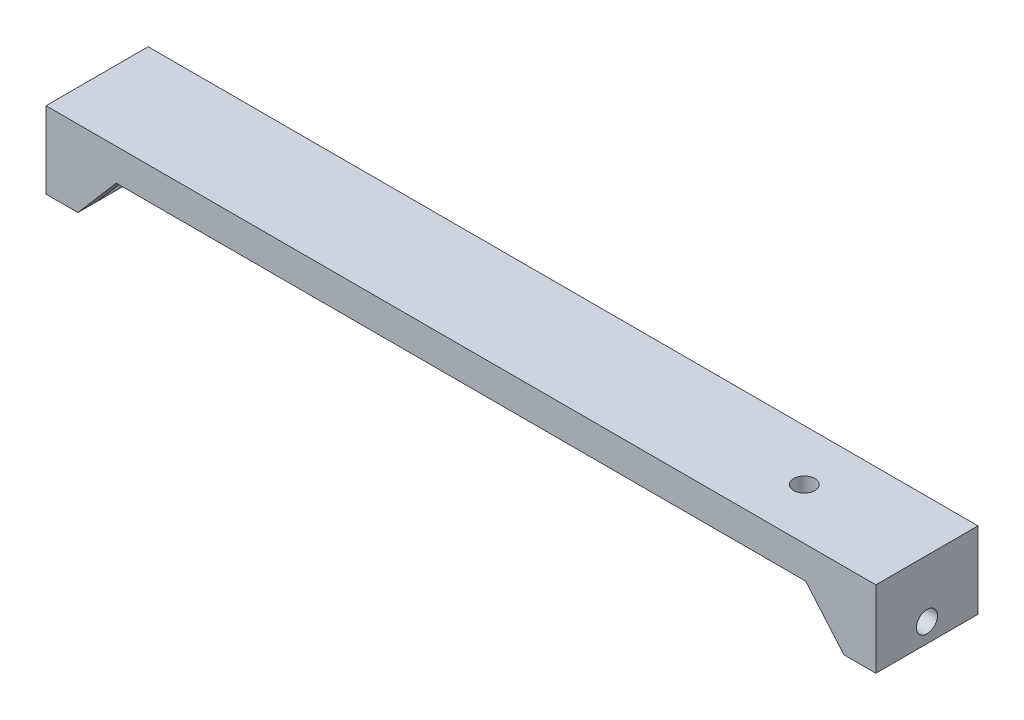
from build123d import *

# Parameters (mm, degrees)
EXTRUDE_2_DEPTH          = 16
SKETCH_3_R               = 1.65
CUT_EXTRUDE_1_DEPTH      = 126
CUT_EXTRUDE_1_DEPTH_BACK = 6
EXTRUDE_3_DEPTH          = 3
MIRROR_2_COPY_1_DEPTH    = 3
SKETCH_7_R               = 1.65
CUT_EXTRUDE_2_DEPTH      = 10


with BuildPart() as part:
    # 草图1 → 凸台-拉伸2 (new body)
    with BuildSketch(Plane.XY):
        Polygon((-65, 0), (65, 0), (65, -12), (60, -12), (60, -5), (-60, -5), (-60, -12), (-65, -12), align=None)
    extrude(amount=EXTRUDE_2_DEPTH)

    # 草图3 → 切除-拉伸1 (cut, two sides)
    with BuildSketch(Plane(origin=(-60, 0, 0), x_dir=(0, 0, -1), z_dir=(1, 0, 0))) as cut_extrude_1_sk:
        with Locations((-8, -9)):
            Circle(SKETCH_3_R)
    extrude(amount=CUT_EXTRUDE_1_DEPTH, mode=Mode.SUBTRACT)
    extrude(cut_extrude_1_sk.sketch, amount=-CUT_EXTRUDE_1_DEPTH_BACK, mode=Mode.SUBTRACT)

    # 草图4 → 凸台-拉伸3 (add)
    with BuildSketch(Plane(origin=(0, 0, 0), x_dir=(-1, 0, 0), z_dir=(0, 0, -1))):
        Polygon((54, -5), (60, -12), (60, -5), align=None)
    extrude_3 = extrude(amount=-EXTRUDE_3_DEPTH)

    # 镜向1: 凸台-拉伸3 across plane
    add(extrude_3.mirror(Plane.XY.offset(8)))

    # 镜向2: 凸台-拉伸3 across plane
    add(extrude_3.mirror(Plane(origin=(0, 0, 0), x_dir=(0, 0, 1), z_dir=(1, 0, 0))))

    # 镜向2 copy 1 sketch → 镜向2 copy 1 (add)
    with BuildSketch(Plane.XY.offset(16)):
        Polygon((54, -5), (60, -12), (60, -5), align=None)
    extrude(amount=-MIRROR_2_COPY_1_DEPTH)

    # 草图7 → 切除-拉伸2 (cut)
    with BuildSketch(Plane(origin=(0, 0, 0), x_dir=(1, 0, 0), z_dir=(0, 1, 0))):
        with Locations((45.79, -8)):
            Circle(SKETCH_7_R)
    extrude(amount=-CUT_EXTRUDE_2_DEPTH, mode=Mode.SUBTRACT)


solid = part.part
